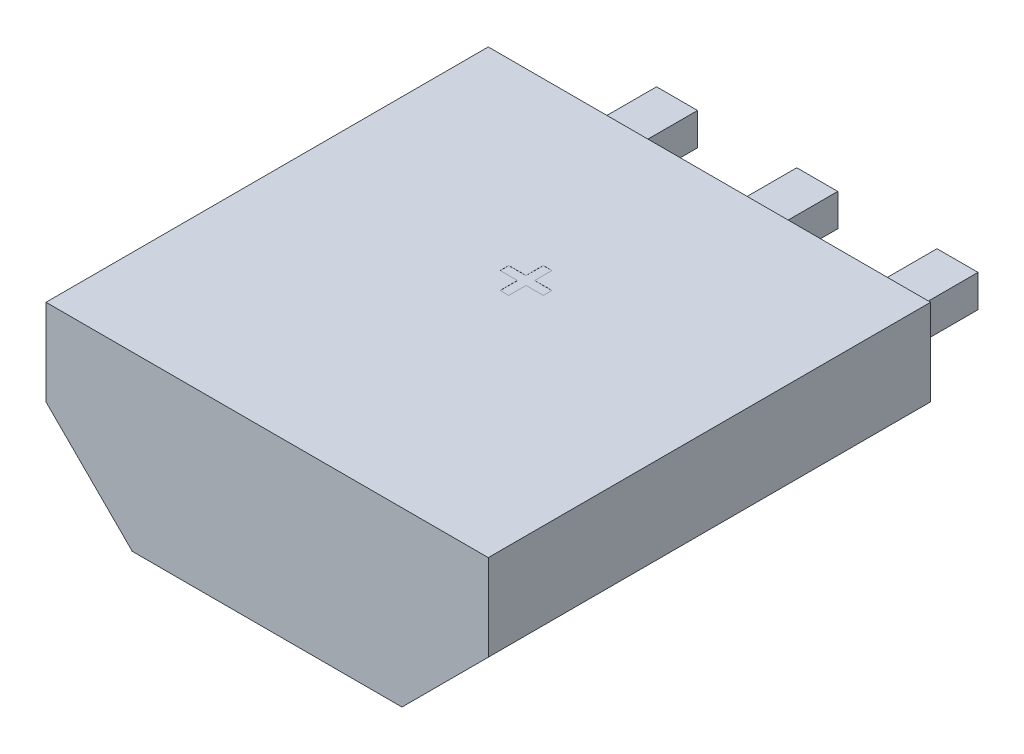
from build123d import *

# Parameters (mm, degrees)
BOITIER_DEPTH           = 4.1
ESQUISSE2_W             = 0.38
ESQUISSE2_H             = 0.3
PIN2_DEPTH              = 1
ESQUISSE3_W             = 0.38
ESQUISSE3_H             = 0.3
PIN3_DEPTH              = 1
ESQUISSE4_W             = 0.38
ESQUISSE4_H             = 0.3
PIN1_DEPTH              = 1
ESQUISSE5_R             = 0.2
ENL_V_MAT_EXTRU_1_DEPTH = 0.001
ENL_V_MAT_EXTRU_4_DEPTH = 0.001


with BuildPart() as part:
    # Esquisse1 → Boitier (new body)
    with BuildSketch(Plane.XY.offset(4.1)):
        Polygon((-2.05, -0.8), (-1.25, -1.6), (1.25, -1.6), (2.05, -0.8), (2.05, 0), (-2.05, 0), align=None)
    extrude(amount=-BOITIER_DEPTH)

    # Esquisse2 → Pin2 (add)
    with BuildSketch(Plane(origin=(0, 0, 0), x_dir=(-1, 0, 0), z_dir=(0, 0, -1))):
        with Locations((0, -0.69)):
            Rectangle(ESQUISSE2_W, ESQUISSE2_H)
    extrude(amount=PIN2_DEPTH)

    # Esquisse3 → Pin3 (add)
    with BuildSketch(Plane(origin=(0, 0, 0), x_dir=(-1, 0, 0), z_dir=(0, 0, -1))):
        with Locations((-1.3, -0.69)):
            Rectangle(ESQUISSE3_W, ESQUISSE3_H)
    extrude(amount=PIN3_DEPTH)

    # Esquisse4 → Pin1 (add)
    with BuildSketch(Plane(origin=(0, 0, 0), x_dir=(-1, 0, 0), z_dir=(0, 0, -1))):
        with Locations((1.3, -0.69)):
            Rectangle(ESQUISSE4_W, ESQUISSE4_H)
    extrude(amount=PIN1_DEPTH)

    # Esquisse5 → Enlèv. mat.-Extru.1 (cut)
    with BuildSketch(Plane.XZ.offset(1.6)):
        with Locations((0, 1.7)):
            Circle(ESQUISSE5_R)
    extrude(amount=-ENL_V_MAT_EXTRU_1_DEPTH, mode=Mode.SUBTRACT)

    # Esquisse6 → Enlèv. mat.-Extru.4 (cut)
    with BuildSketch(Plane(origin=(0, 0, 0), x_dir=(1, 0, 0), z_dir=(0, 1, 0))):
        Polygon((-0.2, -1.66), (-0.04, -1.66), (-0.04, -1.5), (0.04, -1.5), (0.04, -1.66), (0.2, -1.66), (0.2, -1.74), (0.04, -1.74), (0.04, -1.9), (-0.04, -1.9), (-0.04, -1.74), (-0.2, -1.74), align=None)
    extrude(amount=-ENL_V_MAT_EXTRU_4_DEPTH, mode=Mode.SUBTRACT)


solid = part.part
